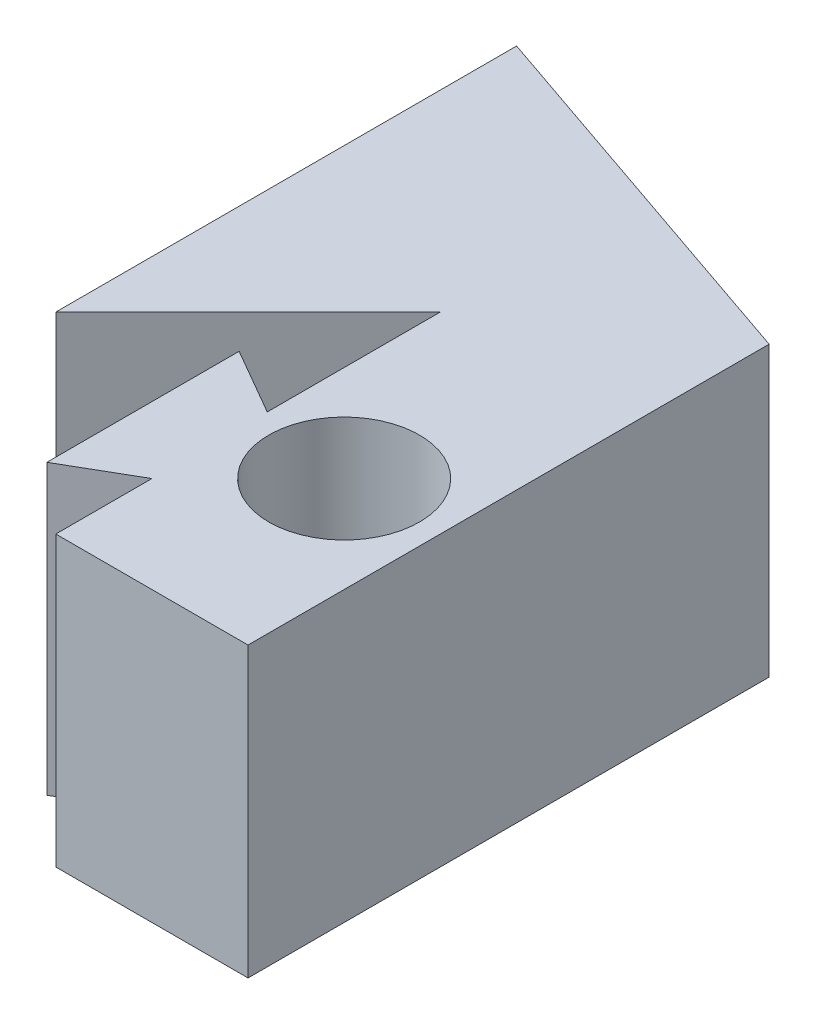
from build123d import *

# Parameters (mm, degrees)
SKETCH2_R               = 2.4892
BOSS_EXTRUDE3_DEPTH     = 9.525
SKETCH3_R               = 2.4892
BOSS_EXTRUDE4_DEPTH     = 9.525
SKETCH4_W               = 12.7
SKETCH4_H               = 1.27
BOSS_EXTRUDE5_DEPTH     = 9.525
SKETCH5_R               = 2.4892
CUT_EXTRUDE1_DEPTH      = 1
CUT_EXTRUDE1_DEPTH_BACK = 10.525
BOSS_EXTRUDE7_DEPTH     = 9.525


with BuildPart() as part:
    # Sketch2 → Boss-Extrude3 (new body)
    with BuildSketch(Plane(origin=(0, 0, 0), x_dir=(1, 0, 0), z_dir=(0, 1, 0))):
        with Locations((6.35, 6.35)):
            Circle(SKETCH2_R)
    extrude(amount=BOSS_EXTRUDE3_DEPTH)

    # Sketch3 → Boss-Extrude4 (add)
    with BuildSketch(Plane(origin=(0, 9.525, 0), x_dir=(1, 0, 0), z_dir=(0, 1, 0))):
        Polygon((9.525, 12.7), (3.175, 12.7), (3.175, 6.985), (0.975295474, 8.255), (0.975295474, 1.905), (3.175, 3.175), (3.175, 0), (9.525, 0), align=None)
        with Locations((6.35, 6.35)):
            Circle(SKETCH3_R, mode=Mode.SUBTRACT)
        Polygon((-3.175, 12.7), (-3.175, 6.35), (3.175, 12.7), align=None)
    extrude(amount=-BOSS_EXTRUDE4_DEPTH)

    # Sketch4 → Boss-Extrude5 (add)
    with BuildSketch(Plane(origin=(0, 9.525, 0), x_dir=(1, 0, 0), z_dir=(0, 1, 0))):
        with Locations((3.175, 13.335)):
            Rectangle(SKETCH4_W, SKETCH4_H)
    extrude(amount=-BOSS_EXTRUDE5_DEPTH)

    # Sketch5 → Cut-Extrude1 (cut, two sides)
    with BuildSketch(Plane(origin=(0, 9.525, 0), x_dir=(1, 0, 0), z_dir=(0, 1, 0))) as cut_extrude1_sk:
        with Locations((6.35, 6.35)):
            Circle(SKETCH5_R)
    extrude(amount=CUT_EXTRUDE1_DEPTH, mode=Mode.SUBTRACT)
    extrude(cut_extrude1_sk.sketch, amount=-CUT_EXTRUDE1_DEPTH_BACK, mode=Mode.SUBTRACT)

    # Sketch7 → Boss-Extrude7 (add)
    with BuildSketch(Plane(origin=(0, 9.525, 0), x_dir=(1, 0, 0), z_dir=(0, 1, 0))):
        Polygon((9.525, 13.97), (9.525, 17.212483646), (-3.175, 21.571193519), (-3.175, 13.97), align=None)
    extrude(amount=-BOSS_EXTRUDE7_DEPTH)


solid = part.part
